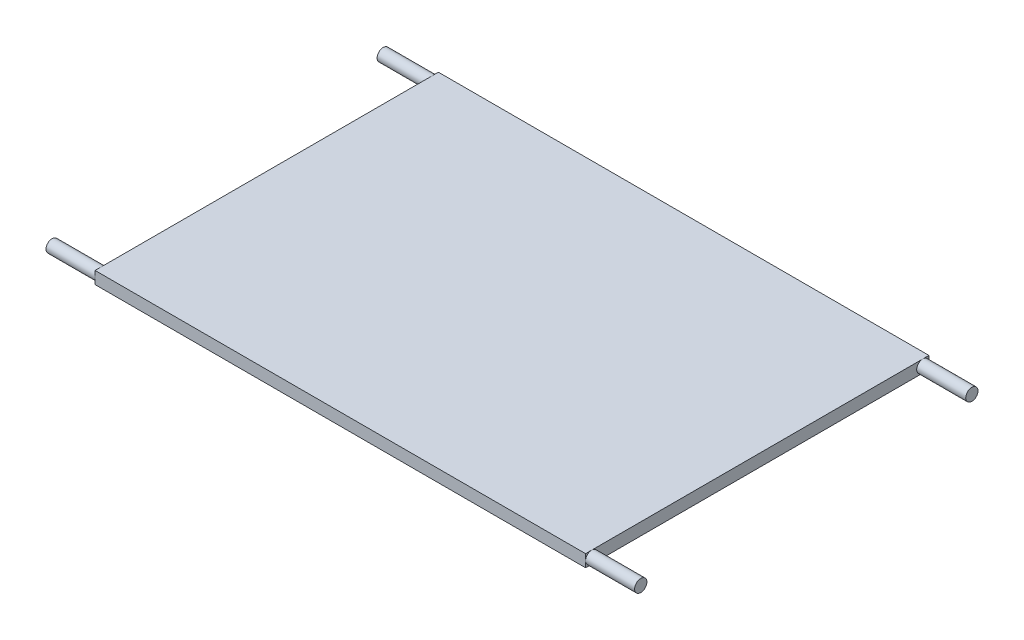
from build123d import *

# Parameters (mm, degrees)
ESQUISSE1_W        = 200
ESQUISSE1_H        = 140
BOSS_EXTRU_1_DEPTH = 5
ESQUISSE3_R        = 2.5
BOSS_EXTRU_2_DEPTH = 20
ESQUISSE4_R        = 2.5
BOSS_EXTRU_3_DEPTH = 20
ESQUISSE6_R        = 2.5
BOSS_EXTRU_4_DEPTH = 20
ESQUISSE8_R        = 2.5
BOSS_EXTRU_5_DEPTH = 20


with BuildPart() as part:
    # Esquisse1 → Boss.-Extru.1 (new body)
    with BuildSketch(Plane(origin=(0, 0, 0), x_dir=(1, 0, 0), z_dir=(0, 1, 0))):
        Rectangle(ESQUISSE1_W, ESQUISSE1_H)
    extrude(amount=BOSS_EXTRU_1_DEPTH)

    # Esquisse3 → Boss.-Extru.2 (add)
    with BuildSketch(Plane.ZY.offset(100)):
        with Locations((67.5, 2.5)):
            Circle(ESQUISSE3_R)
    extrude(amount=BOSS_EXTRU_2_DEPTH)

    # Esquisse4 → Boss.-Extru.3 (add)
    with BuildSketch(Plane(origin=(100, 0, 0), x_dir=(0, 0, -1), z_dir=(1, 0, 0))):
        with Locations((-67.5, 2.5)):
            Circle(ESQUISSE4_R)
    extrude(amount=BOSS_EXTRU_3_DEPTH)

    # Esquisse6 → Boss.-Extru.4 (add)
    with BuildSketch(Plane.ZY.offset(100)):
        with Locations((-67.5, 2.5)):
            Circle(ESQUISSE6_R)
    extrude(amount=BOSS_EXTRU_4_DEPTH)

    # Esquisse8 → Boss.-Extru.5 (add)
    with BuildSketch(Plane(origin=(100, 0, 0), x_dir=(0, 0, -1), z_dir=(1, 0, 0))):
        with Locations((67.5, 2.5)):
            Circle(ESQUISSE8_R)
    extrude(amount=BOSS_EXTRU_5_DEPTH)


solid = part.part
